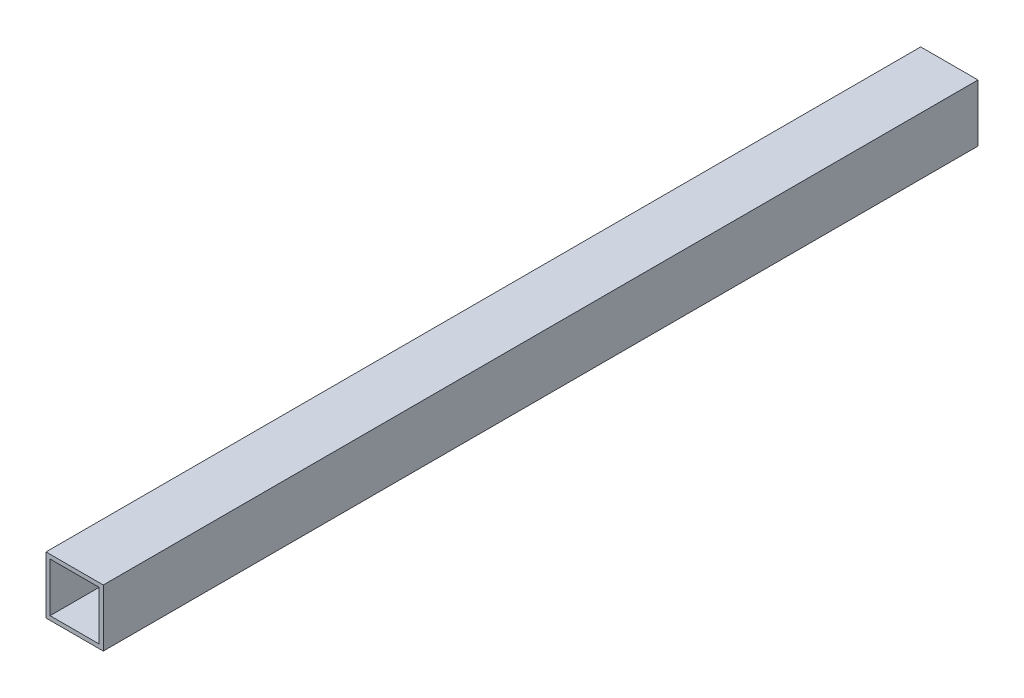
from build123d import *

# Parameters (mm, degrees)
SKETCH1_W           = 44.45
SKETCH1_H           = 44.45
SKETCH1_W_2         = 38.1
SKETCH1_H_2         = 38.1
BOSS_EXTRUDE1_DEPTH = 678.815


with BuildPart() as part:
    # Sketch1 → Boss-Extrude1 (new body)
    with BuildSketch(Plane.XY):
        Rectangle(SKETCH1_W, SKETCH1_H)
        Rectangle(SKETCH1_W_2, SKETCH1_H_2, mode=Mode.SUBTRACT)
    extrude(amount=BOSS_EXTRUDE1_DEPTH)


solid = part.part
